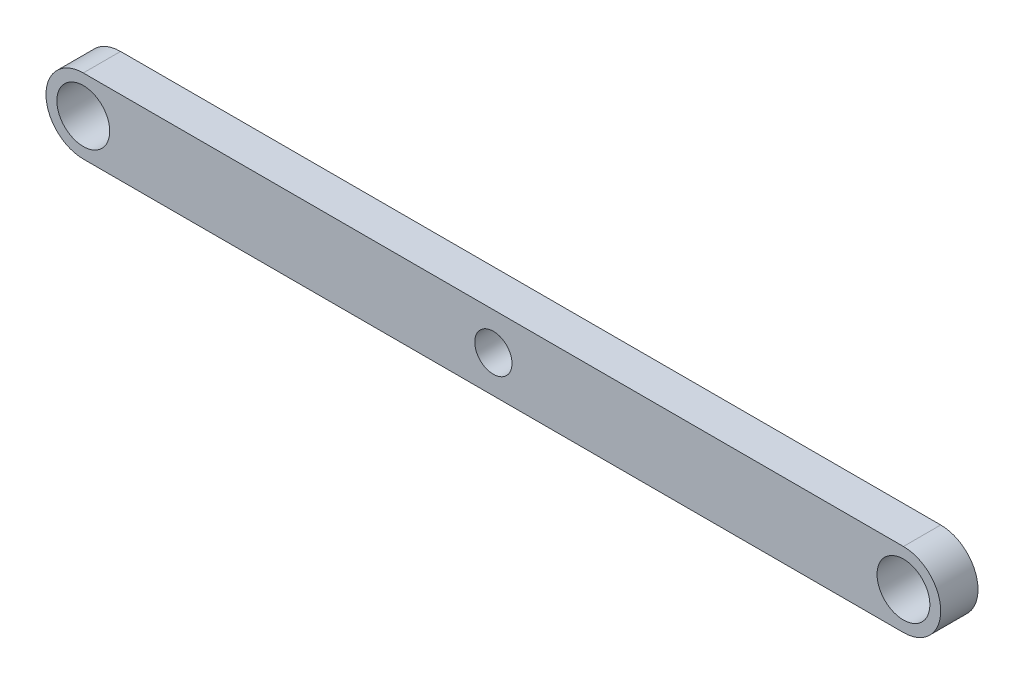
from build123d import *

# Parameters (mm, degrees)
SKETCH1_R           = 4.5
SKETCH1_R_2         = 3.175
BOSS_EXTRUDE1_DEPTH = 6.35


with BuildPart() as part:
    # Sketch1 → Boss-Extrude1 (new body)
    with BuildSketch(Plane.XY):
        with BuildLine():
            Line((-69.85, 6.35), (69.85, 6.35))
            ThreePointArc((69.85, 6.35), (76.2, 0), (69.85, -6.35))
            Line((69.85, -6.35), (-69.85, -6.35))
            ThreePointArc((-69.85, -6.35), (-76.2, 0), (-69.85, 6.35))
        make_face()
        with Locations((-69.85, 0)):
            Circle(SKETCH1_R, mode=Mode.SUBTRACT)
        with Locations((69.85, 0)):
            Circle(SKETCH1_R, mode=Mode.SUBTRACT)
        Circle(SKETCH1_R_2, mode=Mode.SUBTRACT)
    extrude(amount=BOSS_EXTRUDE1_DEPTH)


solid = part.part
